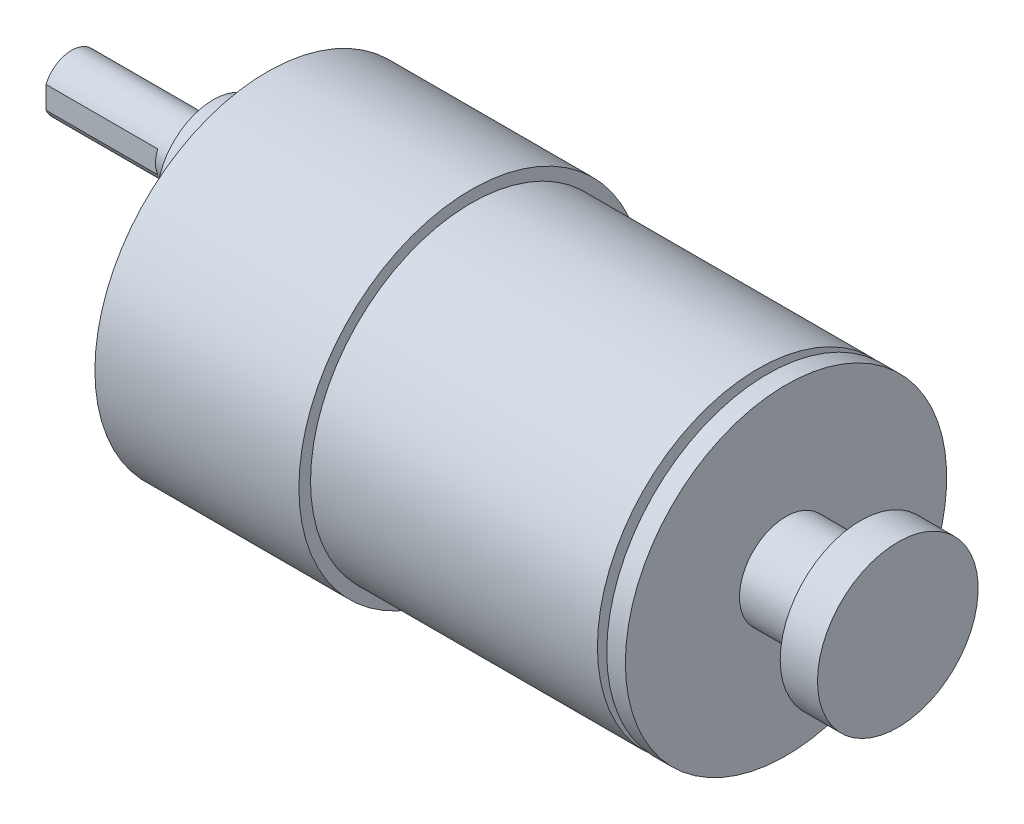
from build123d import *

# Parameters (mm, degrees)
CUT_EXTRUDE1_DEPTH        = 12
M3X0_5_TAPPED_HOLE1_D     = 2.5
M3X0_5_TAPPED_HOLE1_DEPTH = 8.5
M3X0_5_TAPPED_HOLE1_TIP   = 0.751075774
CUT_EXTRUDE2_DEPTH        = 2


with BuildPart() as part:
    # Sketch1 → MainBody (revolve)
    with BuildSketch(Plane.XY):
        Polygon((0, 0), (0, 8.625), (-4, 8.625), (-4, 5), (-12, 5), (-12, 17.25), (-14, 17.25), (-14, 5), (-15, 5), (-15, 17.25), (-45.8, 17.25), (-45.8, 18.5), (-67.7, 18.5), (-67.7, 0), align=None)
    revolve(axis=Axis((-80.111398028, 0, 0), (1, 0, 0)))

    # Sketch3 → SmallBoss (revolve)
    with BuildSketch(Plane.XY):
        Polygon((-67.7, 7), (-67.7, 13), (-73.5, 13), (-73.5, 10), (-88.7, 10), (-88.7, 7), align=None)
    revolve(axis=Axis((0, 7, 0), (-1, 0, 0)))

    # Sketch4 → Cut-Extrude1 (cut)
    with BuildSketch(Plane.ZY.offset(88.7)):
        with BuildLine():
            Line((-2.75, 5.801042119), (-2.75, 8.198957881))
            ThreePointArc((-2.75, 8.198957881), (-3, 7), (-2.75, 5.801042119))
        make_face()
        with BuildLine():
            ThreePointArc((3, 7), (2.936835031, 7.612372436), (2.75, 8.198957881))
            Line((2.75, 8.198957881), (2.75, 5.801042119))
            ThreePointArc((2.75, 5.801042119), (2.936835031, 6.387627564), (3, 7))
        make_face()
    extrude(amount=-CUT_EXTRUDE1_DEPTH, mode=Mode.SUBTRACT)

    # M3x0.5 Tapped Hole1
    with Locations(Plane.ZY.offset(67.7)):
        with Locations((7.75, 13.423393759), (15.5, 0), (7.75, -13.423393759), (-7.75, -13.423393759), (-15.5, 0), (-7.75, 13.423393759)):
            Hole(M3X0_5_TAPPED_HOLE1_D / 2, depth=M3X0_5_TAPPED_HOLE1_DEPTH)
            with Locations((0, 0, -(M3X0_5_TAPPED_HOLE1_DEPTH + M3X0_5_TAPPED_HOLE1_TIP / 2))):  # 118° drill point
                Cone(0, M3X0_5_TAPPED_HOLE1_D / 2, M3X0_5_TAPPED_HOLE1_TIP, mode=Mode.SUBTRACT)

    # Sketch9 → Cut-Extrude2 (cut)
    with BuildSketch(Plane.ZY.offset(67.7)):
        with BuildLine():
            ThreePointArc((-9.324839925, 6.385470704), (-3.342227597, -10.796128493), (11.301631552, 0))
            ThreePointArc((11.301631552, 0), (10.796128493, 3.342227597), (9.324839925, 6.385470704))
            ThreePointArc((9.324839925, 6.385470704), (0, -2.345067463), (-9.324839925, 6.385470704))
        make_face()
    extrude(amount=-CUT_EXTRUDE2_DEPTH, mode=Mode.SUBTRACT)


solid = part.part
